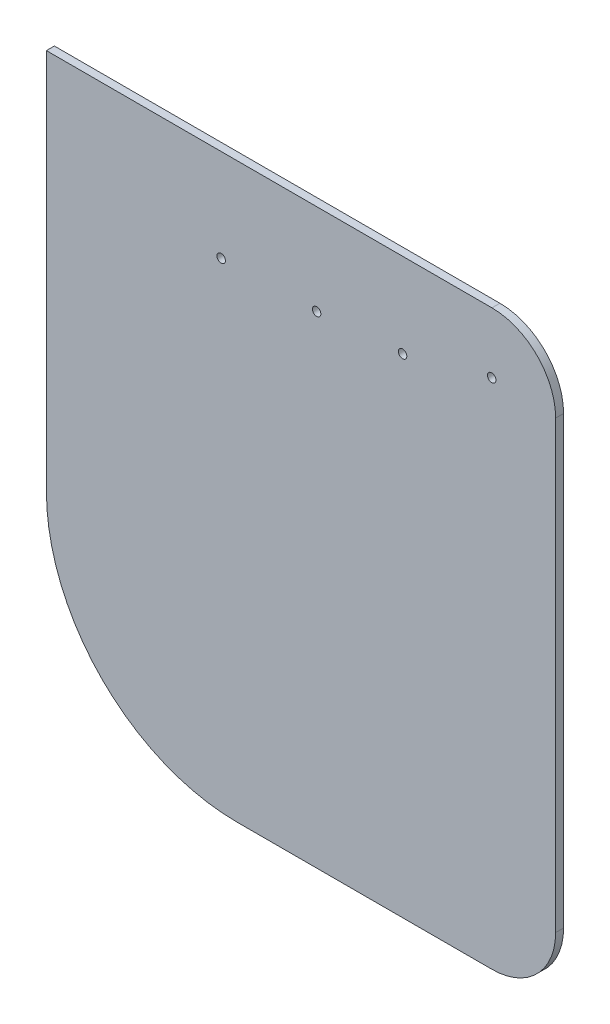
from build123d import *

# Parameters (mm, degrees)
BOSS_EXTRUDE1_DEPTH = 6.35
SKETCH2_R           = 3.3782
CUT_EXTRUDE1_DEPTH  = 6.35


with BuildPart() as part:
    # Sketch1 → Boss-Extrude1 (new body)
    with BuildSketch(Plane.XY):
        with BuildLine():
            Line((-203.2, 228.6), (152.4, 228.6))
            ThreePointArc((152.4, 228.6), (188.321024484, 213.721024484), (203.2, 177.8))
            Line((203.2, 177.8), (203.2, -177.8))
            ThreePointArc((203.2, -177.8), (188.321024484, -213.721024484), (152.4, -228.6))
            Line((152.4, -228.6), (-50.8, -228.6))
            ThreePointArc((-50.8, -228.6), (-158.563073453, -183.963073453), (-203.2, -76.2))
            Line((-203.2, -76.2), (-203.2, 228.6))
        make_face()
    extrude(amount=BOSS_EXTRUDE1_DEPTH)

    # Sketch2 → Cut-Extrude1 (cut)
    with BuildSketch(Plane(origin=(0, 0, 0), x_dir=(-1, 0, 0), z_dir=(0, 0, -1))):
        with Locations((-81.049562296, 161.155935463)):
            Circle(SKETCH2_R)
        with Locations((-152.169562296, 180.205935019)):
            Circle(SKETCH2_R)
        with Locations((63.730437704, 154.805935463)):
            Circle(SKETCH2_R)
        with Locations((-12.469562296, 156.075935463)):
            Circle(SKETCH2_R)
    extrude(amount=-CUT_EXTRUDE1_DEPTH, mode=Mode.SUBTRACT)


solid = part.part
